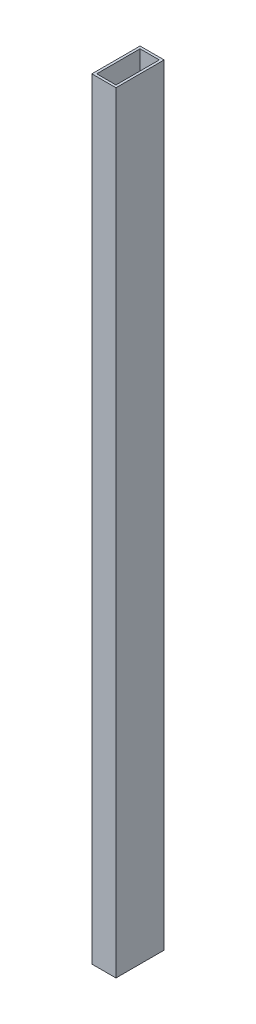
from build123d import *

# Parameters (mm, degrees)
SKETCH1_W           = 10
SKETCH1_H           = 20
SKETCH1_W_2         = 8
SKETCH1_H_2         = 18
BOSS_EXTRUDE1_DEPTH = 320


with BuildPart() as part:
    # Sketch1 → Boss-Extrude1 (new body)
    with BuildSketch(Plane(origin=(0, 0, 0), x_dir=(1, 0, 0), z_dir=(0, 1, 0))):
        Rectangle(SKETCH1_W, SKETCH1_H)
        Rectangle(SKETCH1_W_2, SKETCH1_H_2, mode=Mode.SUBTRACT)
    extrude(amount=BOSS_EXTRUDE1_DEPTH)


solid = part.part
